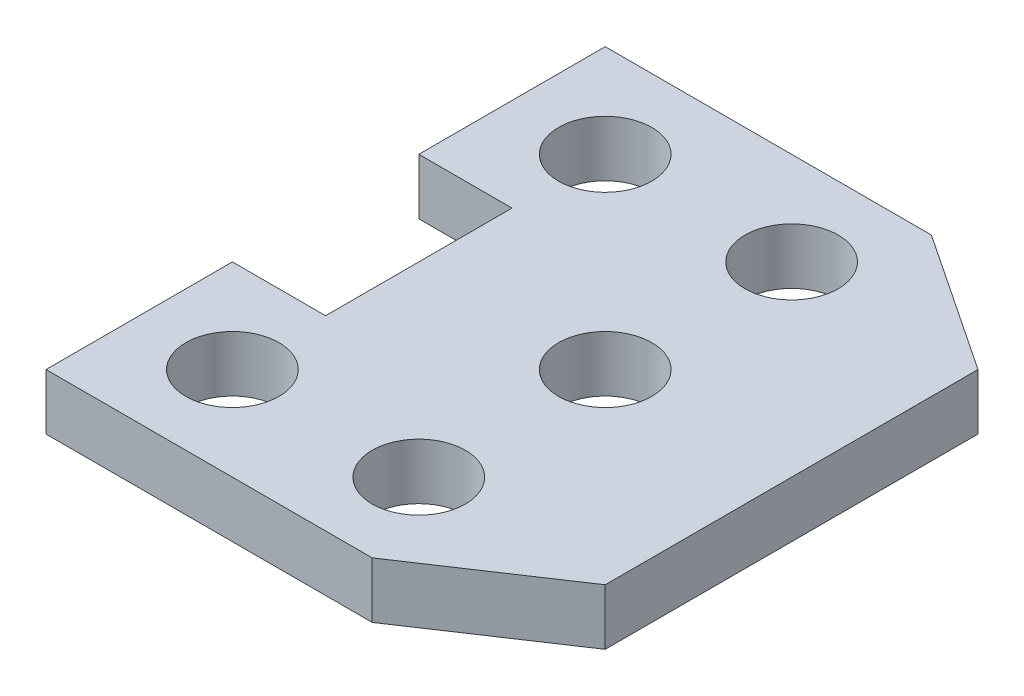
from build123d import *

# Parameters (mm, degrees)
SKETCH2_R           = 10
BOSS_EXTRUDE1_DEPTH = 12


with BuildPart() as part:
    # Sketch2 → Boss-Extrude1 (new body)
    with BuildSketch(Plane(origin=(0, 0, 0), x_dir=(1, 0, 0), z_dir=(0, 1, 0))):
        Polygon((0, 0), (70, 0), (100, 20), (100, 100), (70, 120), (0, 120), (0, 80), (20, 80), (20, 40), (0, 40), align=None)
        with Locations((20, 100)):
            Circle(SKETCH2_R, mode=Mode.SUBTRACT)
        with Locations((60, 100)):
            Circle(SKETCH2_R, mode=Mode.SUBTRACT)
        with Locations((60, 20)):
            Circle(SKETCH2_R, mode=Mode.SUBTRACT)
        with Locations((20, 20)):
            Circle(SKETCH2_R, mode=Mode.SUBTRACT)
        with Locations((60, 60)):
            Circle(SKETCH2_R, mode=Mode.SUBTRACT)
    extrude(amount=BOSS_EXTRUDE1_DEPTH)


solid = part.part
